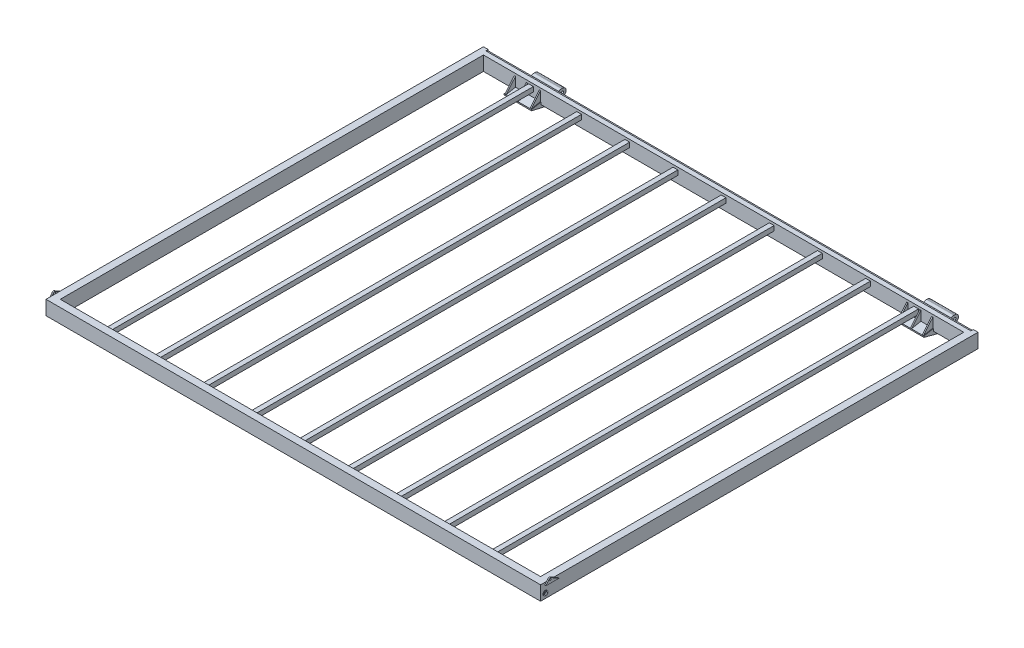
from build123d import *

# Parameters (mm, degrees)
SKETCH1_W                    = 38.1
SKETCH1_H                    = 76.2
SKETCH1_W_2                  = 31.75
SKETCH1_H_2                  = 69.85
LS_PIN_HOUSING_DEPTH         = 146.05
RS_PIN_HOUSING_DEPTH         = 146.05
SKETCH9_R                    = 12.7
LS_CABLE_SUPPORT_DEPTH       = 3.175
SKETCH11_R                   = 12.7
RS_CABLE_SUPPORT_DEPTH       = 3.175
SKETCH3_R                    = 6.35
CANTILVER_PIN_DEPTH          = 2241.55
SKETCH7_W                    = 6.35
SKETCH7_H                    = 50.8
FLANGE_SUPPORT_ANGLE         = 100.62
CUT_EXTRUDE2_DEPTH           = 2235.2
SKETCH12_R                   = 7.9375
RS_BOLT_HOLE_DEPTH           = 9.525
SKETCH10_R                   = 7.9375
LS_BOLT_HOLE_DEPTH           = 9.525
LS_FARWALL_PIN_SUPPORT_DEPTH = 6.35
RS_FARWALL_PIN_SUPPORT_DEPTH = 6.35
SKETCH14_R                   = 4.7625
FARWALL_PIN_HOLE_DEPTH       = 2654.3
SKETCH17_W                   = 25.4
SKETCH17_H                   = 25.4
SKETCH17_W_2                 = 19.05
SKETCH17_H_2                 = 19.05
CROSS_SUPPORTS_DEPTH         = 2260.346
SKETCH18_W                   = 2603.5
SKETCH18_H                   = 12.7
BOSS_EXTRUDE1_DEPTH          = 19.05
SKETCH19_W                   = 2590.8
SKETCH19_H                   = 6.35
CUT_EXTRUDE4_DEPTH           = 12.7


with BuildPart() as part:
    # FLOOR FRAM: sweep along a path in Sketch2
    with BuildLine(Plane(origin=(0, 0, 0), x_dir=(1, 0, 0), z_dir=(0, 1, 0))) as floor_fram_path:
        Line((1301.75, 1149.223), (-1301.75, 1149.223))
        Line((-1301.75, 1149.223), (-1301.75, -1149.223))
        Line((-1301.75, -1149.223), (1301.75, -1149.223))
        Line((1301.75, -1149.223), (1301.75, 1149.223))
    # Sketch1 → FLOOR FRAM (sweep)
    with BuildSketch(Plane(origin=(0, 0, 0), x_dir=(0, 0, -1), z_dir=(1, 0, 0))):
        with Locations((1149.223, 0)):
            Rectangle(SKETCH1_W, SKETCH1_H)
        with Locations((1149.223, 0)):
            Rectangle(SKETCH1_W_2, SKETCH1_H_2, mode=Mode.SUBTRACT)
    sweep(path=floor_fram_path.line, transition=Transition.RIGHT)

    # Sketch4 → LS PIN HOUSING (add)
    with BuildSketch(Plane(origin=(1120.775, 0, 0), x_dir=(0, 0, -1), z_dir=(1, 0, 0))):
        with BuildLine():
            Line((1168.273, -38.1), (1168.472204897, -38.299204897))
            ThreePointArc((1168.472204897, -38.299204897), (1171.768346121, -40.50161605), (1175.656409794, -41.275))
            Line((1175.656409794, -41.275), (1181.90963715, -41.275))
            ThreePointArc((1181.90963715, -41.275), (1184.095578949, -41.037059184), (1186.179133981, -40.334381585))
            Line((1186.179133981, -40.334381585), (1224.523028302, -22.577319056))
            ThreePointArc((1224.523028302, -22.577319056), (1232.336359672, -19.94227806), (1240.533641418, -19.05))
            Line((1240.533641418, -19.05), (1244.839780729, -19.05))
            ThreePointArc((1244.839780729, -19.05), (1258.310164911, -24.629615818), (1263.889780729, -38.1))
            Line((1263.889780729, -38.1), (1263.889780729, -38.762353946))
            ThreePointArc((1263.889780729, -38.762353946), (1260.832816087, -48.730334175), (1252.713106955, -55.27066951))
            Line((1252.713106955, -55.27066951), (1238.952375922, -60.774961923))
            ThreePointArc((1238.952375922, -60.774961923), (1232.007387709, -62.812538334), (1224.802391153, -63.5))
            Line((1224.802391153, -63.5), (1167.307379805, -63.5))
            ThreePointArc((1167.307379805, -63.5), (1162.332734682, -63.173838909), (1157.443262035, -62.200939942))
            Line((1157.443262035, -62.200939942), (1079.373, -41.275))
            Line((1079.373, -41.275), (1079.373, -34.925))
            Line((1079.373, -34.925), (1130.173, -25.4))
            Line((1130.173, -25.4), (1130.173, -38.1))
            Line((1130.173, -38.1), (1168.273, -38.1))
        make_face()
    extrude(amount=-LS_PIN_HOUSING_DEPTH)

    # Sketch6 → RS PIN HOUSING (add)
    with BuildSketch(Plane(origin=(-1120.775, 0, 0), x_dir=(0, 0, -1), z_dir=(1, 0, 0))):
        with BuildLine():
            Line((1168.273, -38.1), (1178.374498247, -40.904667776))
            ThreePointArc((1178.374498247, -40.904667776), (1179.720986285, -41.181991224), (1181.0925867, -41.275))
            Line((1181.0925867, -41.275), (1181.90963715, -41.275))
            ThreePointArc((1181.90963715, -41.275), (1184.095578949, -41.037059184), (1186.179133981, -40.334381585))
            Line((1186.179133981, -40.334381585), (1224.523028302, -22.577319056))
            ThreePointArc((1224.523028302, -22.577319056), (1232.336359672, -19.94227806), (1240.533641418, -19.05))
            Line((1240.533641418, -19.05), (1244.839780729, -19.05))
            ThreePointArc((1244.839780729, -19.05), (1258.310164911, -24.629615818), (1263.889780729, -38.1))
            Line((1263.889780729, -38.1), (1263.889780729, -38.762353946))
            ThreePointArc((1263.889780729, -38.762353946), (1260.832816087, -48.730334175), (1252.713106955, -55.27066951))
            Line((1252.713106955, -55.27066951), (1238.952375922, -60.774961923))
            ThreePointArc((1238.952375922, -60.774961923), (1232.007387709, -62.812538334), (1224.802391153, -63.5))
            Line((1224.802391153, -63.5), (1183.79952302, -63.5))
            ThreePointArc((1183.79952302, -63.5), (1179.651836455, -63.273561968), (1175.553451412, -62.596939431))
            Line((1175.553451412, -62.596939431), (1079.373, -41.275))
            Line((1079.373, -41.275), (1079.373, -34.925))
            Line((1079.373, -34.925), (1130.173, -25.4))
            Line((1130.173, -25.4), (1130.173, -38.1))
            Line((1130.173, -38.1), (1168.273, -38.1))
        make_face()
    extrude(amount=RS_PIN_HOUSING_DEPTH)

    # Sketch9 → LS CABLE SUPPORT (add, symmetric)
    with BuildSketch(Plane(origin=(1320.8, 0, 0), x_dir=(0, 0, -1), z_dir=(1, 0, 0))):
        with Locations((-1142.873, -12.7)):
            Circle(SKETCH9_R)
    extrude(amount=LS_CABLE_SUPPORT_DEPTH, both=True)

    # Sketch11 → RS CABLE SUPPORT (add, symmetric)
    with BuildSketch(Plane.ZY.offset(1320.8)):
        with Locations((1142.873, -12.7)):
            Circle(SKETCH11_R)
    extrude(amount=RS_CABLE_SUPPORT_DEPTH, both=True)

    # Sketch3 → CANTILVER PIN (cut)
    with BuildSketch(Plane(origin=(1120.775, 0, 0), x_dir=(0, 0, -1), z_dir=(1, 0, 0))):
        with Locations((1244.727, -38.1)):
            Circle(SKETCH3_R)
    extrude(amount=-CANTILVER_PIN_DEPTH, mode=Mode.SUBTRACT)

    # Sketch7 → FLANGE SUPPORT (revolve)
    with BuildSketch(Plane(origin=(0, -229.247939623, -42.983988679), x_dir=(1, 0, 0), z_dir=(0, 0.982872187, 0.184288535))):
        with Locations((-1050.925, 1080.734679334)):
            Rectangle(SKETCH7_W, SKETCH7_H)
        with Locations((-1114.425, 1080.734679334)):
            Rectangle(SKETCH7_W, SKETCH7_H)
        with Locations((-981.075, 1080.734679334)):
            Rectangle(SKETCH7_W, SKETCH7_H)
        with Locations((1050.925, 1080.734679334)):
            Rectangle(SKETCH7_W, SKETCH7_H)
        with Locations((981.075, 1080.734679334)):
            Rectangle(SKETCH7_W, SKETCH7_H)
        with Locations((1114.425, 1080.734679334)):
            Rectangle(SKETCH7_W, SKETCH7_H)
    revolve(axis=Axis((-974.725, -25.4, -1130.173), (-1, 0, 0)), revolution_arc=FLANGE_SUPPORT_ANGLE)

    # Sketch8 → Cut-Extrude2 (cut)
    with BuildSketch(Plane(origin=(1117.6, 0, 0), x_dir=(0, 0, -1), z_dir=(1, 0, 0))):
        with BuildLine():
            Line((1080.243092904, -34.761857581), (1130.173, 25.4))
            ThreePointArc((1130.173, 25.4), (1090.21467467, 7.762464586), (1080.243092904, -34.761857581))
        make_face()
    extrude(amount=-CUT_EXTRUDE2_DEPTH, mode=Mode.SUBTRACT)

    # Sketch12 → RS BOLT HOLE (cut)
    with BuildSketch(Plane.ZY.offset(1323.975)):
        with Locations((1142.873, -12.7)):
            Circle(SKETCH12_R)
    extrude(amount=-RS_BOLT_HOLE_DEPTH, mode=Mode.SUBTRACT)

    # Sketch10 → LS BOLT HOLE (cut)
    with BuildSketch(Plane(origin=(1323.975, 0, 0), x_dir=(0, 0, -1), z_dir=(1, 0, 0))):
        with Locations((-1142.873, -12.7)):
            Circle(SKETCH10_R)
    extrude(amount=-LS_BOLT_HOLE_DEPTH, mode=Mode.SUBTRACT)

    # Sketch15 → LS FARWALL PIN SUPPORT (add)
    with BuildSketch(Plane(origin=(1320.8, 0, 0), x_dir=(0, 0, -1), z_dir=(1, 0, 0))):
        with BuildLine():
            Line((-1128.477247217, 47.766018933), (-1146.048, 25.4))
            Line((-1146.048, 25.4), (-1076.198, 25.4))
            Line((-1076.198, 25.4), (-1117.583757823, 49.29407842))
            ThreePointArc((-1117.583757823, 49.29407842), (-1123.338119815, 50.723042971), (-1128.477247217, 47.766018933))
        make_face()
    extrude(amount=LS_FARWALL_PIN_SUPPORT_DEPTH)

    # Sketch16 → RS FARWALL PIN SUPPORT (add)
    with BuildSketch(Plane.ZY.offset(1320.8)):
        with BuildLine():
            Line((1128.50222821, 47.734052503), (1145.921, 25.326676516))
            Line((1145.921, 25.326676516), (1076.071, 25.326676516))
            Line((1076.071, 25.326676516), (1117.583757823, 49.29407842))
            ThreePointArc((1117.583757823, 49.29407842), (1123.358204408, 50.720199476), (1128.50222821, 47.734052503))
        make_face()
    extrude(amount=RS_FARWALL_PIN_SUPPORT_DEPTH)

    # Sketch14 → FARWALL PIN HOLE (cut)
    with BuildSketch(Plane(origin=(1327.15, 0, 0), x_dir=(0, 0, -1), z_dir=(1, 0, 0))):
        with Locations((-1122.2355, 42.8625)):
            Circle(SKETCH14_R)
    extrude(amount=-FARWALL_PIN_HOLE_DEPTH, mode=Mode.SUBTRACT)

    # Sketch17 → CROSS SUPPORTS (add)
    with BuildSketch(Plane.XY.offset(-1130.173)):
        with Locations((-1028.7, 12.7)):
            Rectangle(SKETCH17_W, SKETCH17_H)
        with Locations((-1028.7, 12.7)):
            Rectangle(SKETCH17_W_2, SKETCH17_H_2, mode=Mode.SUBTRACT)
        with Locations((-771.525, 12.7)):
            Rectangle(SKETCH17_W, SKETCH17_H)
        with Locations((-771.525, 12.7)):
            Rectangle(SKETCH17_W_2, SKETCH17_H_2, mode=Mode.SUBTRACT)
        with Locations((-514.35, 12.7)):
            Rectangle(SKETCH17_W, SKETCH17_H)
        with Locations((-514.35, 12.7)):
            Rectangle(SKETCH17_W_2, SKETCH17_H_2, mode=Mode.SUBTRACT)
        with Locations((-257.175, 12.7)):
            Rectangle(SKETCH17_W, SKETCH17_H)
        with Locations((-257.175, 12.7)):
            Rectangle(SKETCH17_W_2, SKETCH17_H_2, mode=Mode.SUBTRACT)
        with Locations((0, 12.7)):
            Rectangle(SKETCH17_W, SKETCH17_H)
        with Locations((0, 12.7)):
            Rectangle(SKETCH17_W_2, SKETCH17_H_2, mode=Mode.SUBTRACT)
        with Locations((257.175, 12.7)):
            Rectangle(SKETCH17_W, SKETCH17_H)
        with Locations((257.175, 12.7)):
            Rectangle(SKETCH17_W_2, SKETCH17_H_2, mode=Mode.SUBTRACT)
        with Locations((514.35, 12.7)):
            Rectangle(SKETCH17_W, SKETCH17_H)
        with Locations((514.35, 12.7)):
            Rectangle(SKETCH17_W_2, SKETCH17_H_2, mode=Mode.SUBTRACT)
        with Locations((771.525, 12.7)):
            Rectangle(SKETCH17_W, SKETCH17_H)
        with Locations((771.525, 12.7)):
            Rectangle(SKETCH17_W_2, SKETCH17_H_2, mode=Mode.SUBTRACT)
        with Locations((1028.7, 12.7)):
            Rectangle(SKETCH17_W, SKETCH17_H)
        with Locations((1028.7, 12.7)):
            Rectangle(SKETCH17_W_2, SKETCH17_H_2, mode=Mode.SUBTRACT)
    extrude(amount=CROSS_SUPPORTS_DEPTH)

    # Sketch18 → Boss-Extrude1 (add)
    with BuildSketch(Plane(origin=(0, 0, -1168.273), x_dir=(-1, 0, 0), z_dir=(0, 0, -1))):
        with Locations((0, 31.75)):
            Rectangle(SKETCH18_W, SKETCH18_H)
    extrude(amount=-BOSS_EXTRUDE1_DEPTH)

    # Sketch19 → Cut-Extrude4 (cut)
    with BuildSketch(Plane(origin=(0, 0, -1168.273), x_dir=(-1, 0, 0), z_dir=(0, 0, -1))):
        with Locations((0, 34.925)):
            Rectangle(SKETCH19_W, SKETCH19_H)
    extrude(amount=-CUT_EXTRUDE4_DEPTH, mode=Mode.SUBTRACT)


solid = part.part
